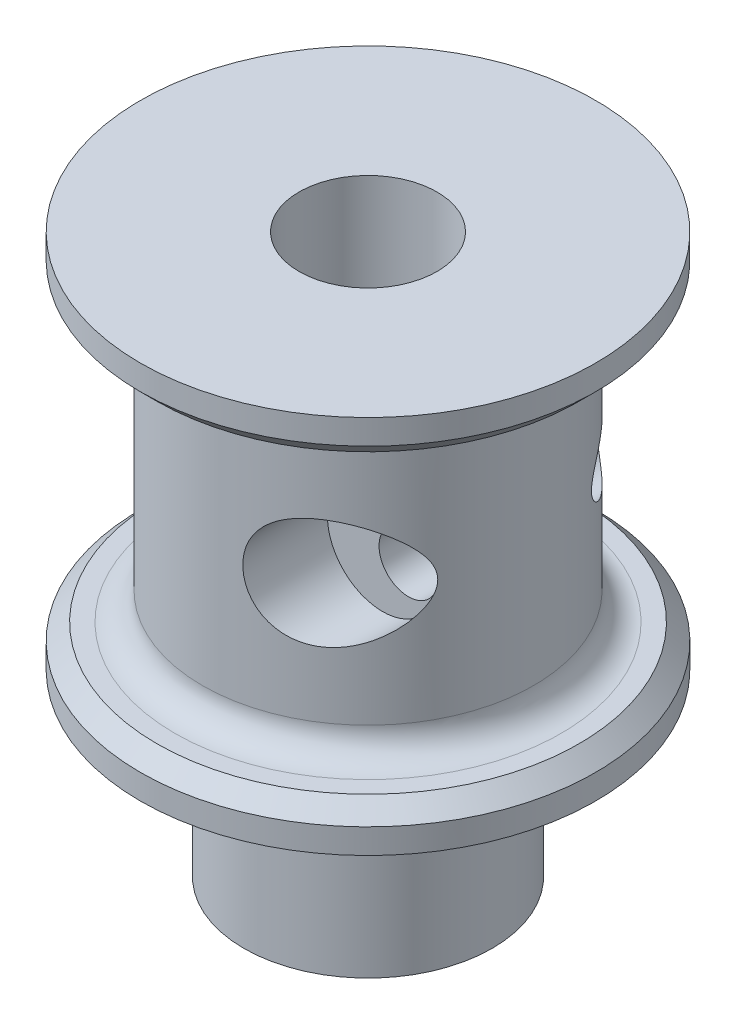
from build123d import *

# Parameters (mm, degrees)
F_10_24_TAPPED_HOLE1_D  = 3.7973
CHAMFER1_SIZE           = 1.905
FILLET1_R               = 3.175
SKETCH5_R               = 7.9375
CUT_EXTRUDE2_DEPTH      = 56.67375
SKETCH6_R               = 3.3782
CUT_EXTRUDE3_DEPTH      = 27.19375
CUT_EXTRUDE3_DEPTH_BACK = 27.19375
CUT_EXTRUDE4_START      = 8.845327
SKETCH7_R               = 6.35
CUT_EXTRUDE4_DEPTH      = 18.348423


with BuildPart() as part:
    # Sketch1 → Revolve1 (revolve)
    with BuildSketch(Plane.XY):
        Polygon((0, 0), (14.2875, 0), (14.2875, 20.6375), (26.19375, 20.6375), (26.19375, 25.4), (19.05, 25.4), (19.05, 59.53125), (26.19375, 59.53125), (26.19375, 64.29375), (0, 64.29375), align=None)
    revolve(axis=Axis((0, 64.29375, 0), (0, -1, 0)))

    # 10-24 Tapped Hole1 (through all)
    with Locations(Plane(origin=(0, 64.29375, 0), x_dir=(1, 0, 0), z_dir=(0, 1, 0))):
        with Locations((0, 0)):
            Hole(F_10_24_TAPPED_HOLE1_D / 2)

    # Chamfer1
    chamfer1_edges = [part.edges().sort_by_distance(p)[0] for p in [
        (-26.19375, 59.53125, 0),
        (-26.19375, 25.4, 0),
    ]]
    chamfer(chamfer1_edges, length=CHAMFER1_SIZE)

    # Fillet1
    fillet1_edges = [part.edges().sort_by_distance(p)[0] for p in [
        (-19.05, 59.53125, 0),
        (-19.05, 25.4, 0),
    ]]
    fillet(fillet1_edges, radius=FILLET1_R)

    # Sketch5 → Cut-Extrude2 (cut)
    with BuildSketch(Plane(origin=(0, 64.29375, 0), x_dir=(1, 0, 0), z_dir=(0, 1, 0))):
        Circle(SKETCH5_R)
    extrude(amount=-CUT_EXTRUDE2_DEPTH, mode=Mode.SUBTRACT)

    # Sketch6 → Cut-Extrude3 (cut, two sides)
    with BuildSketch(Plane.XY) as cut_extrude3_sk:
        with Locations((13.49375, 42.465625)):
            Circle(SKETCH6_R)
    extrude(amount=CUT_EXTRUDE3_DEPTH, mode=Mode.SUBTRACT)
    extrude(cut_extrude3_sk.sketch, amount=-CUT_EXTRUDE3_DEPTH_BACK, mode=Mode.SUBTRACT)

    # Sketch7 → Cut-Extrude4 (cut, through all)
    with BuildSketch(Plane.XY.offset(CUT_EXTRUDE4_START)):
        with Locations((10.52195, 42.465625)):
            Circle(SKETCH7_R)
    extrude(amount=CUT_EXTRUDE4_DEPTH, mode=Mode.SUBTRACT)


solid = part.part
